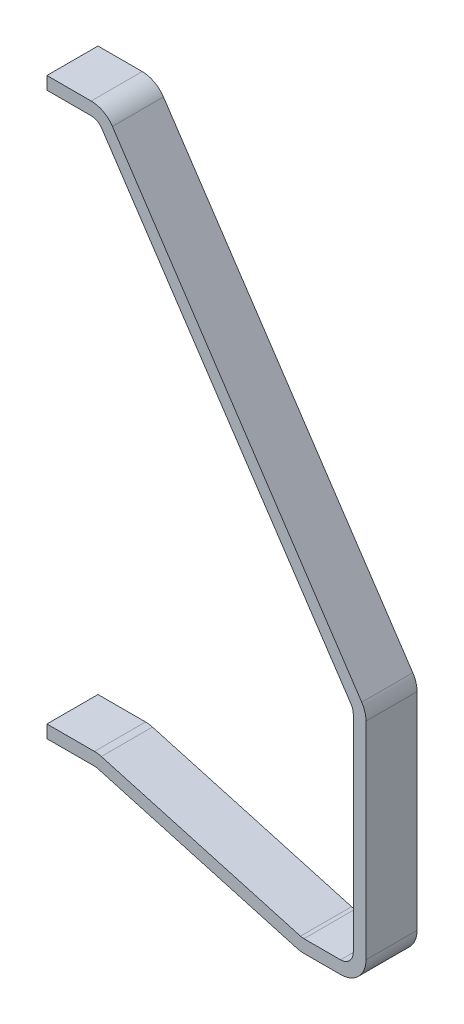
from build123d import *

# Parameters (mm, degrees)
EXTRUDE_THIN1_DEPTH = 25.4
FILLET1_R           = 6.35
FILLET2_R           = 12.7


with BuildPart() as part:
    # Sketch1 → Extrude-Thin1 (new body)
    with BuildSketch(Plane.XY):
        Polygon((0, 0), (25.4, 0), (152.4, -190.5), (152.4, -301.625), (127, -301.625), (25.4, -273.05), (0, -273.05), (0, -279.4), (24.52402436, -279.4), (126.12402436, -307.975), (158.75, -307.975), (158.75, -188.5773747), (28.798416866, 6.35), (0, 6.35), align=None)
    extrude(amount=EXTRUDE_THIN1_DEPTH)

    # Fillet1
    fillet1_edges = [part.edges().sort_by_distance(p)[0] for p in [
        (127, -301.625, 12.7),
        (152.4, -301.625, 12.7),
        (152.4, -190.5, 12.7),
        (25.4, 0, 12.7),
        (24.52402436, -279.4, 12.7),
    ]]
    fillet(fillet1_edges, radius=FILLET1_R)

    # Fillet2
    fillet2_edges = [part.edges().sort_by_distance(p)[0] for p in [
        (25.4, -273.05, 12.7),
        (28.798416866, 6.35, 12.7),
        (158.75, -188.5773747, 12.7),
        (158.75, -307.975, 12.7),
        (126.12402436, -307.975, 12.7),
    ]]
    fillet(fillet2_edges, radius=FILLET2_R)


solid = part.part
